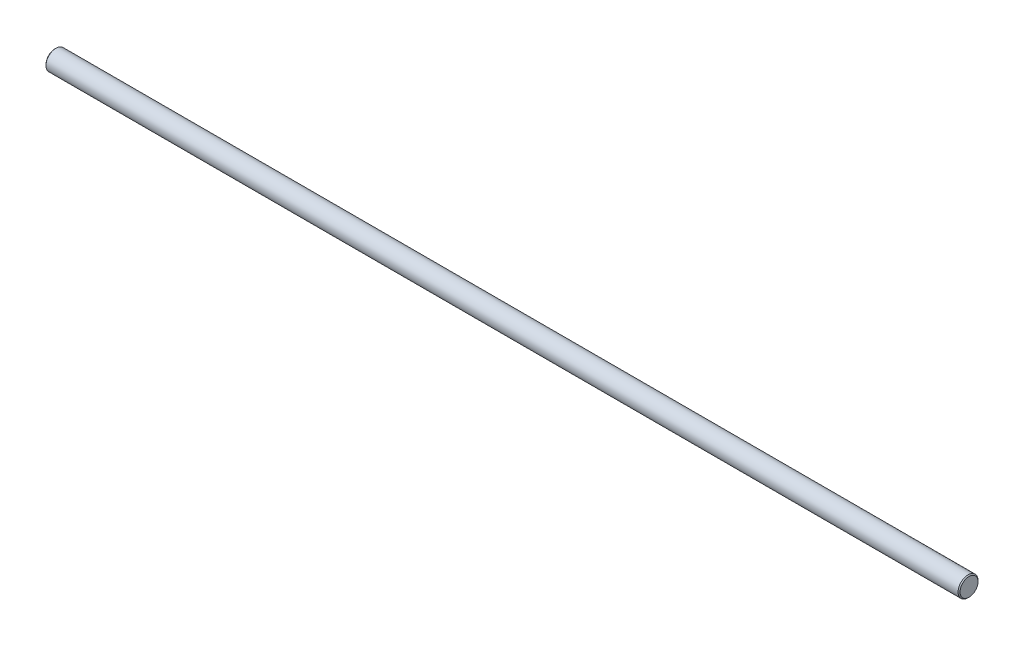
from build123d import *


with BuildPart() as part:
    # Sketch1 → Revolve1 (revolve)
    with BuildSketch(Plane.XY):
        Polygon((0, 0), (0, 4.5), (0.5, 5), (457.5, 5), (458, 4.5), (458, 0), align=None)
    revolve(axis=Axis((458, 0, 0), (-1, 0, 0)))


solid = part.part
